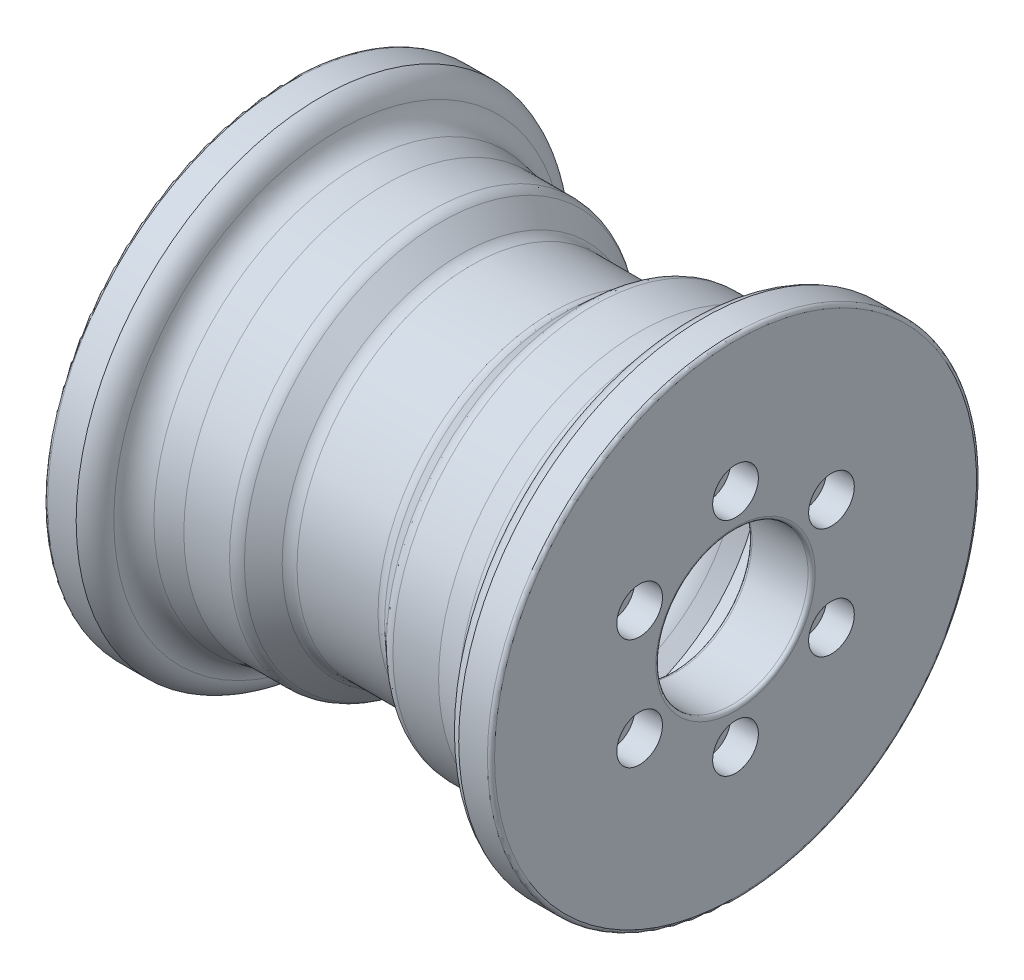
from build123d import *

# Parameters (mm, degrees)
CBORE_FOR_M20_SHCS1_D           = 18.206896552
CBORE_FOR_M20_SHCS1_CBORE_D     = 27.310344828
CBORE_FOR_M20_SHCS1_CBORE_DEPTH = 16.551724138
CIRPATTERN1_COUNT               = 6
MIRROR1_COPY_1_D                = 18.206896552
MIRROR1_COPY_1_CBORE_D          = 27.310344828
MIRROR1_COPY_1_CBORE_DEPTH      = 16.551724138
MIRROR1_COPY_2_D                = 18.206896552
MIRROR1_COPY_2_CBORE_D          = 27.310344828
MIRROR1_COPY_2_CBORE_DEPTH      = 16.551724138
MIRROR1_COPY_3_D                = 18.206896552
MIRROR1_COPY_3_CBORE_D          = 27.310344828
MIRROR1_COPY_3_CBORE_DEPTH      = 16.551724138
MIRROR1_COPY_4_D                = 18.206896552
MIRROR1_COPY_4_CBORE_D          = 27.310344828
MIRROR1_COPY_4_CBORE_DEPTH      = 16.551724138
MIRROR1_COPY_5_D                = 18.206896552
MIRROR1_COPY_5_CBORE_D          = 27.310344828
MIRROR1_COPY_5_CBORE_DEPTH      = 16.551724138


with BuildPart() as part:
    # Sketch1 → Revolve1 (revolve)
    with BuildSketch(Plane(origin=(0, 0, 0), x_dir=(1, 0, 0), z_dir=(0, 1, 0)), mode=Mode.PRIVATE) as revolve1_sk:
        with BuildLine():
            Line((-91.140136318, 122.861823714), (-76.137931034, 120))
            Line((-76.137931034, 120), (-48.827586207, 120))
            ThreePointArc((-48.827586207, 120), (-45.388993837, 119.357101751), (-42.414961507, 117.515263717))
            Line((-42.414961507, 117.515263717), (-30.620689655, 106.760598352))
            ThreePointArc((-30.620689655, 106.760598352), (-27.646657325, 104.918760318), (-24.208064955, 104.275862069))
            Line((-24.208064955, 104.275862069), (0, 104.275862069))
            Line((0, 104.275862069), (24.208064955, 104.275862069))
            ThreePointArc((24.208064955, 104.275862069), (27.646657325, 104.918760318), (30.620689655, 106.760598352))
            Line((30.620689655, 106.760598352), (42.414961507, 117.515263717))
            ThreePointArc((42.414961507, 117.515263717), (45.388993837, 119.357101751), (48.827586207, 120))
            Line((48.827586207, 120), (76.137931034, 120))
            Line((76.137931034, 120), (91.140136318, 122.861823714))
            ThreePointArc((91.140136318, 122.861823714), (99.015817993, 126.903243109), (103.45602139, 134.56118189))
            ThreePointArc((103.45602139, 134.56118189), (107.370018781, 141.795002418), (114.327272727, 146.181818182))
            Line((114.327272727, 146.181818182), (131.47012987, 146.181818182))
            ThreePointArc((131.47012987, 146.181818182), (132.985358687, 145.554189856), (133.612987013, 144.038961039))
            Line((133.612987013, 144.038961039), (133.612987013, 47.660098522))
            ThreePointArc((133.612987013, 47.660098522), (132.985358687, 46.144869705), (131.47012987, 45.517241379))
            Line((131.47012987, 45.517241379), (97.935219203, 45.517241379))
            ThreePointArc((97.935219203, 45.517241379), (96.419990386, 46.144869705), (95.79236206, 47.660098522))
            Line((95.79236206, 47.660098522), (95.79236206, 98.474002316))
            Line((95.79236206, 98.474002316), (78.484828912, 95.172413793))
            Line((78.484828912, 95.172413793), (54.759972878, 95.172413793))
            Line((54.759972878, 95.172413793), (47.349275828, 88.414932883))
            ThreePointArc((47.349275828, 88.414932883), (36.616898289, 81.768299979), (24.208064955, 79.448275862))
            Line((24.208064955, 79.448275862), (0, 79.448275862))
            Line((0, 79.448275862), (-24.208064955, 79.448275862))
            ThreePointArc((-24.208064955, 79.448275862), (-36.616898289, 81.768299979), (-47.349275828, 88.414932883))
            Line((-47.349275828, 88.414932883), (-54.759972878, 95.172413793))
            Line((-54.759972878, 95.172413793), (-78.484828912, 95.172413793))
            Line((-78.484828912, 95.172413793), (-95.79236206, 98.474002316))
            Line((-95.79236206, 98.474002316), (-95.79236206, 47.660098522))
            ThreePointArc((-95.79236206, 47.660098522), (-96.419990386, 46.144869705), (-97.935219203, 45.517241379))
            Line((-97.935219203, 45.517241379), (-131.47012987, 45.517241379))
            ThreePointArc((-131.47012987, 45.517241379), (-132.985358687, 46.144869705), (-133.612987013, 47.660098522))
            Line((-133.612987013, 47.660098522), (-133.612987013, 144.038961039))
            ThreePointArc((-133.612987013, 144.038961039), (-132.985358687, 145.554189856), (-131.47012987, 146.181818182))
            Line((-131.47012987, 146.181818182), (-114.327272727, 146.181818182))
            ThreePointArc((-114.327272727, 146.181818182), (-107.370018781, 141.795002418), (-103.45602139, 134.56118189))
            ThreePointArc((-103.45602139, 134.56118189), (-99.015817993, 126.903243109), (-91.140136318, 122.861823714))
        make_face()
    revolve(revolve1_sk.sketch.rotate(Axis((0, 0, 0), (1, 0, 0)), 180), axis=Axis((0, 0, 0), (1, 0, 0)))

    # CBORE for M20 SHCS1 (through all)
    with Locations(Plane.ZY.offset(133.612987013)):
        with Locations((0, 66.206896552)):
            cbore_for_m20_shcs1 = CounterBoreHole(CBORE_FOR_M20_SHCS1_D / 2, CBORE_FOR_M20_SHCS1_CBORE_D / 2, CBORE_FOR_M20_SHCS1_CBORE_DEPTH)

    # CirPattern1: CBORE for M20 SHCS1 ×6 about axis
    cirpattern1_axis = Axis((0, 0, 0), (1, 0, 0))
    for i in range(1, CIRPATTERN1_COUNT):
        add(cbore_for_m20_shcs1.rotate(cirpattern1_axis, i * 360 / CIRPATTERN1_COUNT), mode=Mode.SUBTRACT)

    # Mirror1: CBORE for M20 SHCS1 across plane
    add(cbore_for_m20_shcs1.mirror(Plane(origin=(0, 0, 0), x_dir=(0, 0, 1), z_dir=(1, 0, 0))), mode=Mode.SUBTRACT)

    # Mirror1 copy 1 (through all)
    with Locations(Plane(origin=(133.612987013, 0, 0), x_dir=(0, -0.8660254037844386, 0.5000000000000001), z_dir=(1, 0, 0))):
        with Locations((0, -66.206896552)):
            CounterBoreHole(MIRROR1_COPY_1_D / 2, MIRROR1_COPY_1_CBORE_D / 2, MIRROR1_COPY_1_CBORE_DEPTH)

    # Mirror1 copy 2 (through all)
    with Locations(Plane(origin=(133.612987013, 0, 0), x_dir=(0, -0.8660254037844387, -0.4999999999999998), z_dir=(1, 0, 0))):
        with Locations((0, -66.206896552)):
            CounterBoreHole(MIRROR1_COPY_2_D / 2, MIRROR1_COPY_2_CBORE_D / 2, MIRROR1_COPY_2_CBORE_DEPTH)

    # Mirror1 copy 3 (through all)
    with Locations(Plane(origin=(133.612987013, 0, 0), x_dir=(0, 0, -1), z_dir=(1, 0, 0))):
        with Locations((0, -66.206896552)):
            CounterBoreHole(MIRROR1_COPY_3_D / 2, MIRROR1_COPY_3_CBORE_D / 2, MIRROR1_COPY_3_CBORE_DEPTH)

    # Mirror1 copy 4 (through all)
    with Locations(Plane(origin=(133.612987013, 0, 0), x_dir=(0, 0.8660254037844384, -0.5000000000000004), z_dir=(1, 0, 0))):
        with Locations((0, -66.206896552)):
            CounterBoreHole(MIRROR1_COPY_4_D / 2, MIRROR1_COPY_4_CBORE_D / 2, MIRROR1_COPY_4_CBORE_DEPTH)

    # Mirror1 copy 5 (through all)
    with Locations(Plane(origin=(133.612987013, 0, 0), x_dir=(0, 0.8660254037844386, 0.5000000000000001), z_dir=(1, 0, 0))):
        with Locations((0, -66.206896552)):
            CounterBoreHole(MIRROR1_COPY_5_D / 2, MIRROR1_COPY_5_CBORE_D / 2, MIRROR1_COPY_5_CBORE_DEPTH)


solid = part.part
